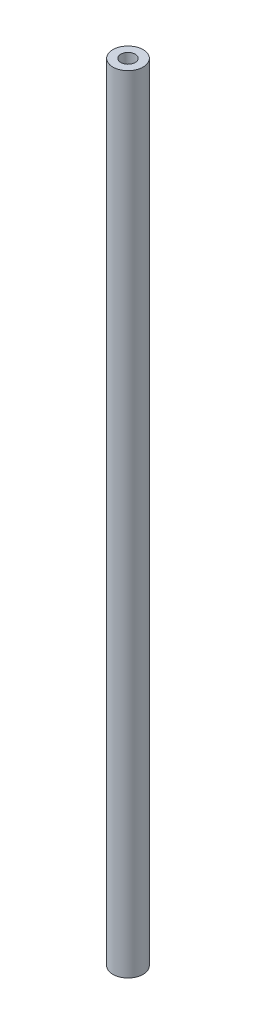
from build123d import *

# Parameters (mm, degrees)
SKETCH1_R           = 3.175
SKETCH1_R_2         = 1.524
BOSS_EXTRUDE1_DEPTH = 165.1


with BuildPart() as part:
    # Sketch1 → Boss-Extrude1 (new body)
    with BuildSketch(Plane(origin=(0, 0, 0), x_dir=(1, 0, 0), z_dir=(0, 1, 0))):
        Circle(SKETCH1_R)
        Circle(SKETCH1_R_2, mode=Mode.SUBTRACT)
    extrude(amount=BOSS_EXTRUDE1_DEPTH)


solid = part.part
